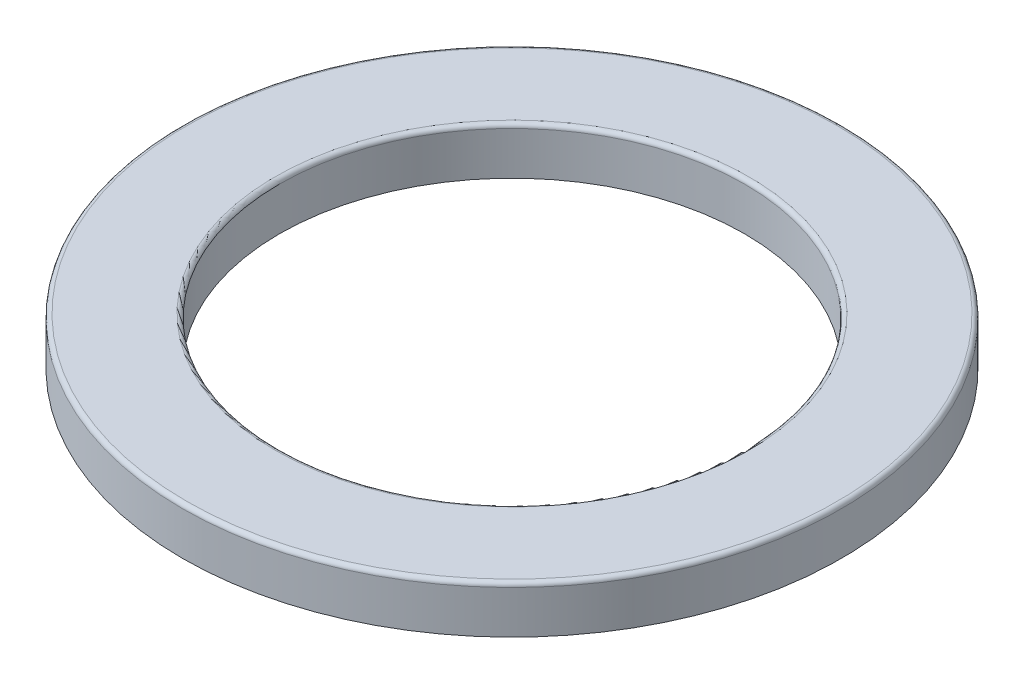
from build123d import *

# Parameters (mm, degrees)
SKETCH1_R           = 85
SKETCH1_R_2         = 60
BOSS_EXTRUDE1_DEPTH = 12.2
FILLET1_R           = 1.1


with BuildPart() as part:
    # Sketch1 → Boss-Extrude1 (new body)
    with BuildSketch(Plane(origin=(0, 0, 0), x_dir=(1, 0, 0), z_dir=(0, 1, 0))):
        Circle(SKETCH1_R)
        Circle(SKETCH1_R_2, mode=Mode.SUBTRACT)
    extrude(amount=BOSS_EXTRUDE1_DEPTH)

    # Fillet1
    fillet1_edges = [part.edges().sort_by_distance(p)[0] for p in [
        (-85, 12.2, 0),
        (-60, 12.2, 0),
    ]]
    fillet(fillet1_edges, radius=FILLET1_R)

    # Sketch2 → Cut-Revolve1 (revolve, cut)
    with BuildSketch(Plane.XY):
        with BuildLine():
            Line((-77.98, 0), (-67.02, 0))
            ThreePointArc((-67.02, 0), (-72.5, 1.827500428), (-77.98, 0))
        make_face()
    revolve(axis=Axis((0, 11.1, 0), (0, -1, 0)), mode=Mode.SUBTRACT)


solid = part.part
